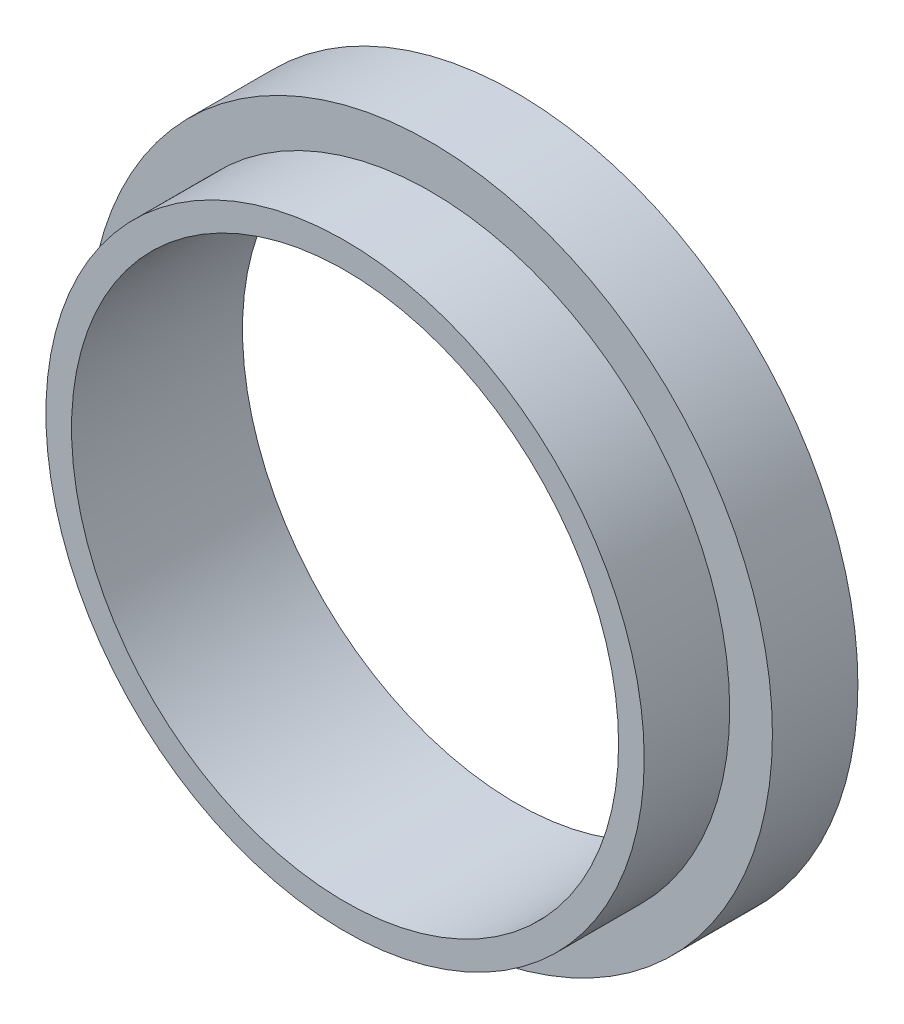
from build123d import *

# Parameters (mm, degrees)
SKETCH1_R           = 35
SKETCH1_R_2         = 32
BOSS_EXTRUDE1_DEPTH = 10
SKETCH2_R           = 40
SKETCH2_R_2         = 32
BOSS_EXTRUDE2_DEPTH = 10


with BuildPart() as part:
    # Sketch1 → Boss-Extrude1 (new body)
    with BuildSketch(Plane.XY):
        Circle(SKETCH1_R)
        Circle(SKETCH1_R_2, mode=Mode.SUBTRACT)
    extrude(amount=BOSS_EXTRUDE1_DEPTH)

    # Sketch2 → Boss-Extrude2 (add)
    with BuildSketch(Plane.XY):
        Circle(SKETCH2_R)
        Circle(SKETCH2_R_2, mode=Mode.SUBTRACT)
    extrude(amount=-BOSS_EXTRUDE2_DEPTH)


solid = part.part
